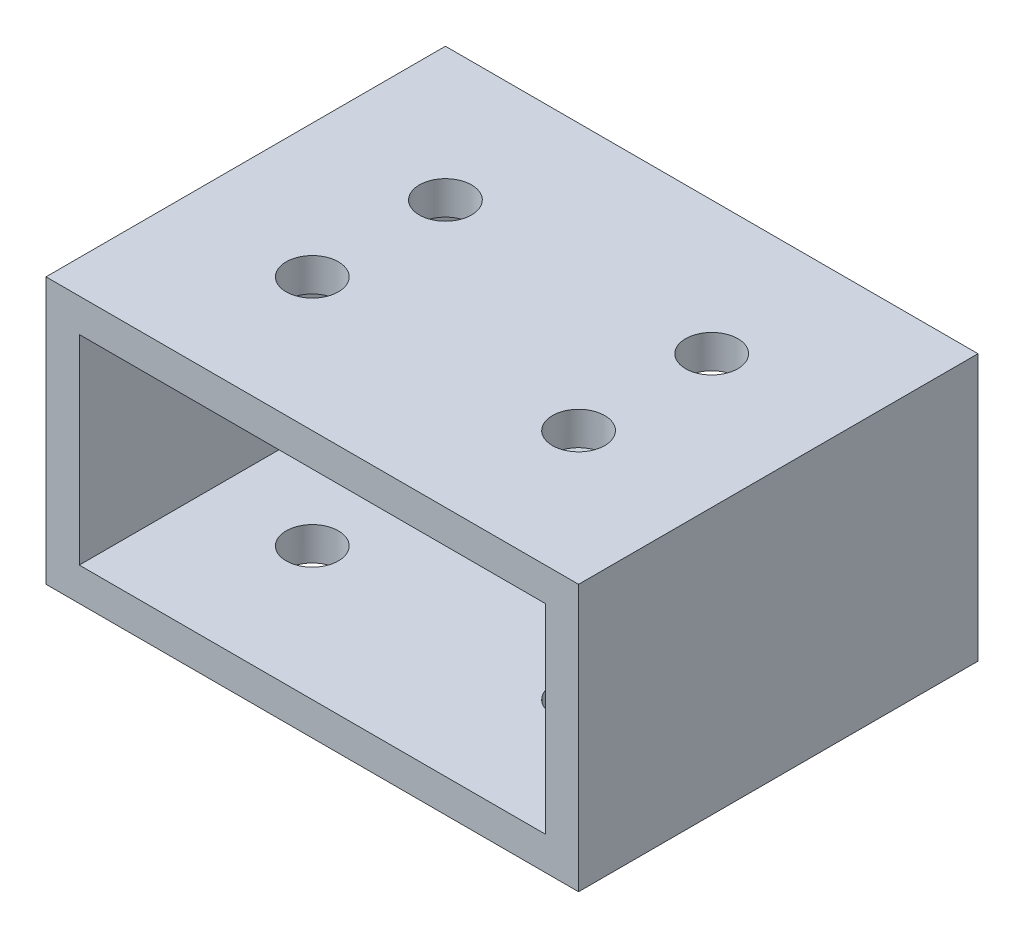
from build123d import *

# Parameters (mm, degrees)
SKETCH1_W           = 50.8
SKETCH1_H           = 25.4
SKETCH1_W_2         = 44.45
SKETCH1_H_2         = 19.05
EXTRUDE_THIN1_DEPTH = 19.05
SKETCH2_R           = 2.4892
CUT_EXTRUDE1_DEPTH  = 26.4


with BuildPart() as part:
    # Sketch1 → Extrude-Thin1 (new body, symmetric)
    with BuildSketch(Plane.XY):
        with Locations((25.4, 12.7)):
            Rectangle(SKETCH1_W, SKETCH1_H)
        with Locations((25.4, 12.7)):
            Rectangle(SKETCH1_W_2, SKETCH1_H_2, mode=Mode.SUBTRACT)
    extrude(amount=EXTRUDE_THIN1_DEPTH, both=True)

    # Sketch2 → Cut-Extrude1 (cut, through all)
    with BuildSketch(Plane(origin=(0, 25.4, 0), x_dir=(1, 0, 0), z_dir=(0, 1, 0))):
        with Locations((38.1, 6.35)):
            Circle(SKETCH2_R)
        with Locations((38.1, -6.35)):
            Circle(SKETCH2_R)
        with Locations((12.7, -6.35)):
            Circle(SKETCH2_R)
        with Locations((12.7, 6.35)):
            Circle(SKETCH2_R)
    extrude(amount=-CUT_EXTRUDE1_DEPTH, mode=Mode.SUBTRACT)


solid = part.part
